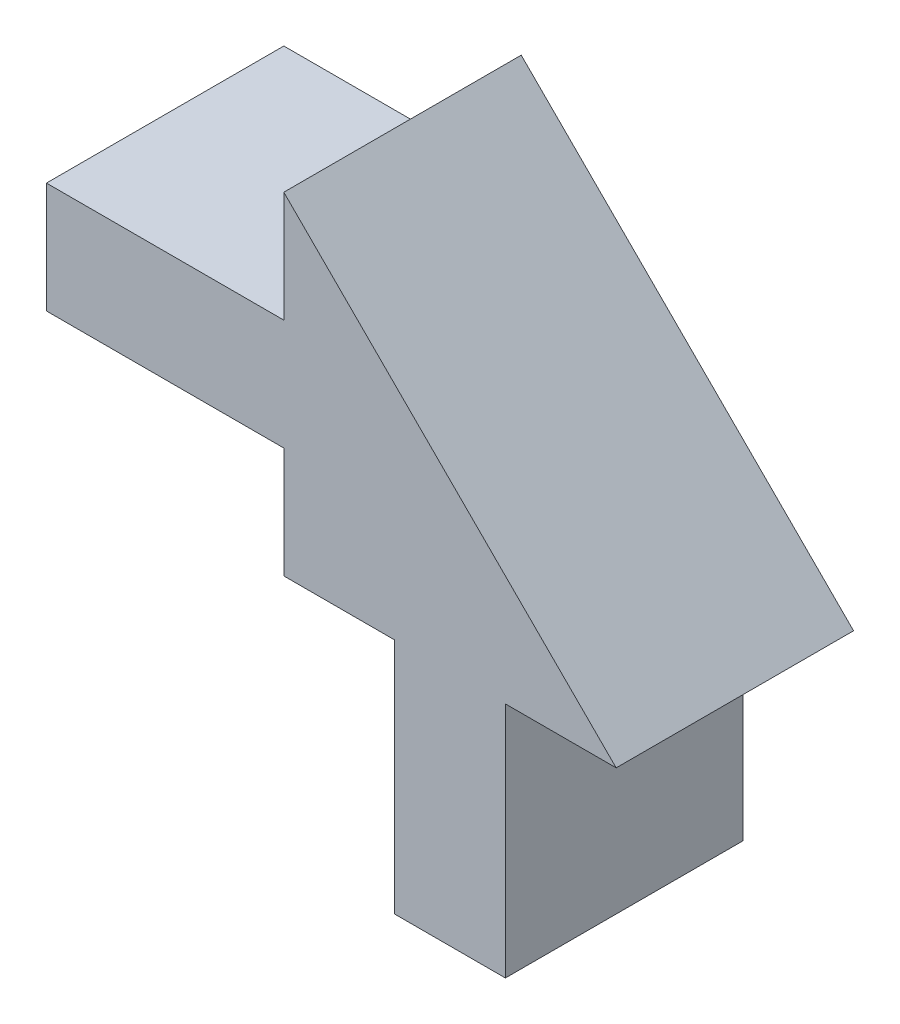
from build123d import *

# Parameters (mm, degrees)
BOSS_EXTRUDE1_DEPTH = 6.35


with BuildPart() as part:
    # Sketch1 → Boss-Extrude1 (new body)
    with BuildSketch(Plane.XY):
        Polygon((0, 8.89), (8.89, 0), (5.926666667, 0), (5.926666667, -6.35), (2.963333333, -6.35), (2.963333333, 0), (0, 0), (0, 2.963333333), (-6.35, 2.963333333), (-6.35, 5.926666667), (0, 5.926666667), align=None)
    extrude(amount=BOSS_EXTRUDE1_DEPTH)


solid = part.part
